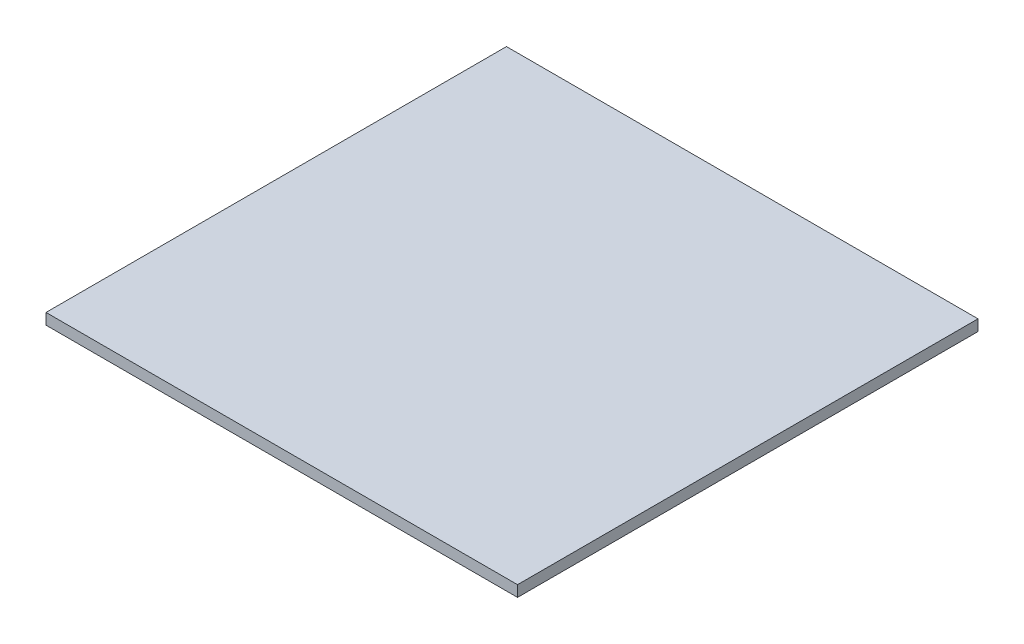
from build123d import *

# Parameters (mm, degrees)
SKETCH1_W           = 203.2
SKETCH1_H           = 198.4375
BOSS_EXTRUDE1_DEPTH = 4.7625


with BuildPart() as part:
    # Sketch1 → Boss-Extrude1 (new body)
    with BuildSketch(Plane(origin=(0, 0, 0), x_dir=(1, 0, 0), z_dir=(0, 1, 0))):
        Rectangle(SKETCH1_W, SKETCH1_H)
    extrude(amount=BOSS_EXTRUDE1_DEPTH)


solid = part.part
